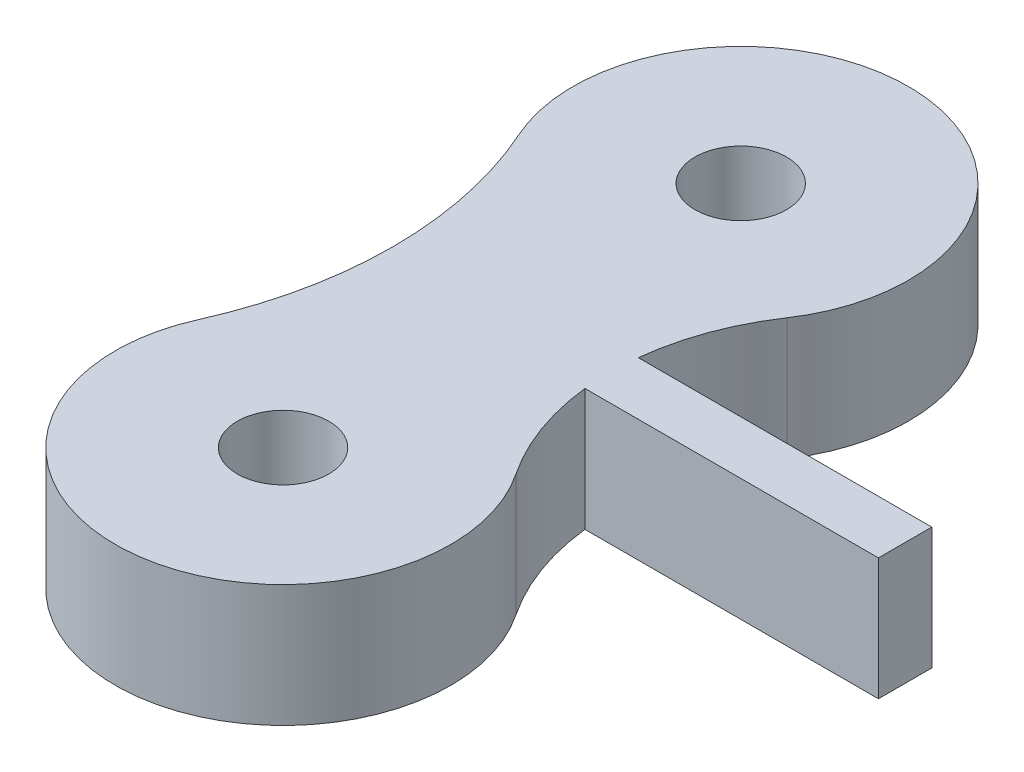
from build123d import *

# Parameters (mm, degrees)
SKETCH1_R           = 1.5
BOSS_EXTRUDE1_DEPTH = 4


with BuildPart() as part:
    # Sketch1 → Boss-Extrude1 (new body)
    with BuildSketch(Plane(origin=(0, 0, 0), x_dir=(1, 0, 0), z_dir=(0, 1, 0))):
        with BuildLine():
            Line((3.268994099, -6.625644187), (12.886719117, -6.625644187))
            Line((12.886719117, -6.625644187), (12.886719117, -8.374355813))
            Line((12.886719117, -8.374355813), (3.268994099, -8.374355813))
            ThreePointArc((3.268994099, -8.374355813), (3.704492519, -10.235637907), (4.570133689, -11.939954566))
            ThreePointArc((4.570133689, -11.939954566), (0.465944189, -20.480227734), (-5.021146674, -12.755431873))
            ThreePointArc((-5.021146674, -12.755431873), (-3.899959484, -7.5), (-5.021146674, -2.244568127))
            ThreePointArc((-5.021146674, -2.244568127), (0.465944189, 5.480227734), (4.570133689, -3.060045434))
            ThreePointArc((4.570133689, -3.060045434), (3.704492519, -4.764362093), (3.268994099, -6.625644187))
        make_face()
        Circle(SKETCH1_R, mode=Mode.SUBTRACT)
        with Locations((0, -15)):
            Circle(SKETCH1_R, mode=Mode.SUBTRACT)
    extrude(amount=BOSS_EXTRUDE1_DEPTH)


solid = part.part
